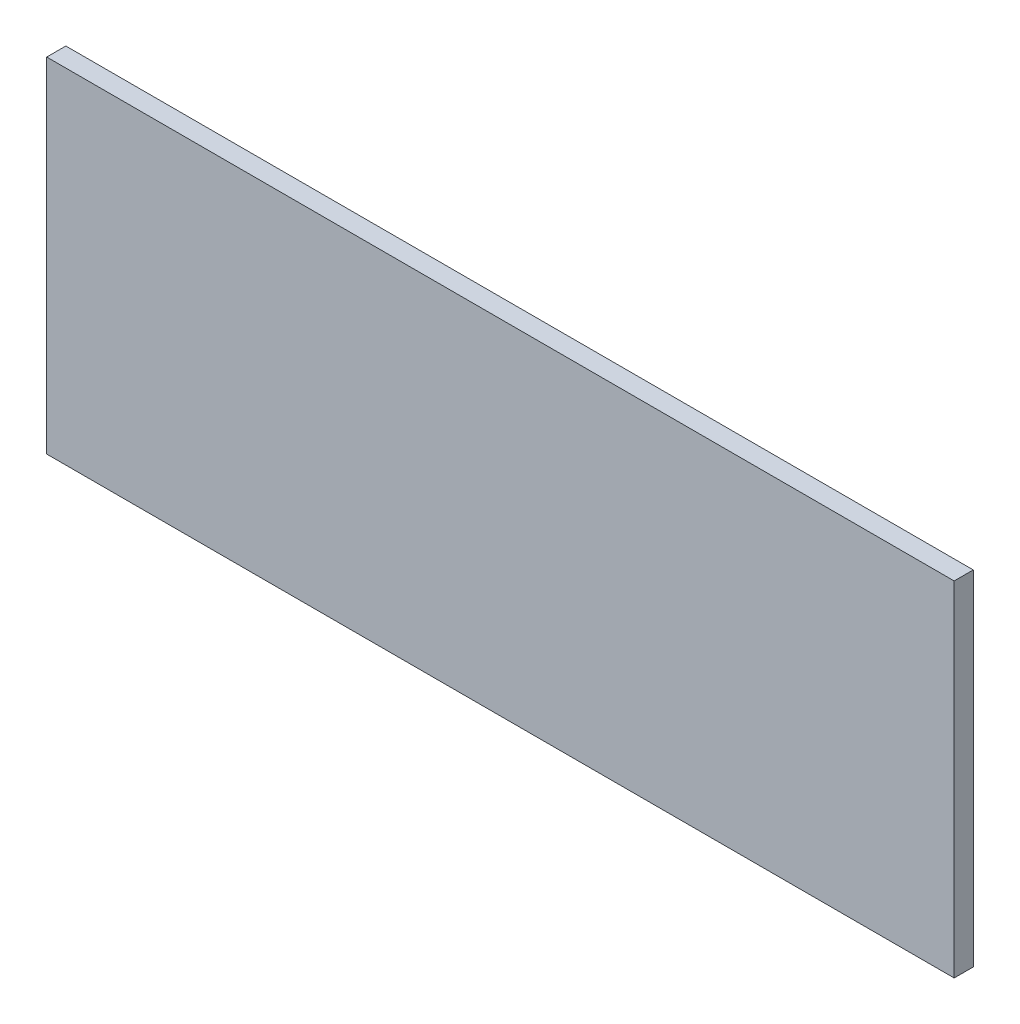
from build123d import *

# Parameters (mm, degrees)
SKIZZE1_W                       = 475
SKIZZE1_H                       = 180
AUFSATZ_LINEAR_AUSTRAGEN1_DEPTH = 10


with BuildPart() as part:
    # Skizze1 → Aufsatz-Linear austragen1 (new body)
    with BuildSketch(Plane.XY):
        Rectangle(SKIZZE1_W, SKIZZE1_H)
    extrude(amount=AUFSATZ_LINEAR_AUSTRAGEN1_DEPTH)


solid = part.part
